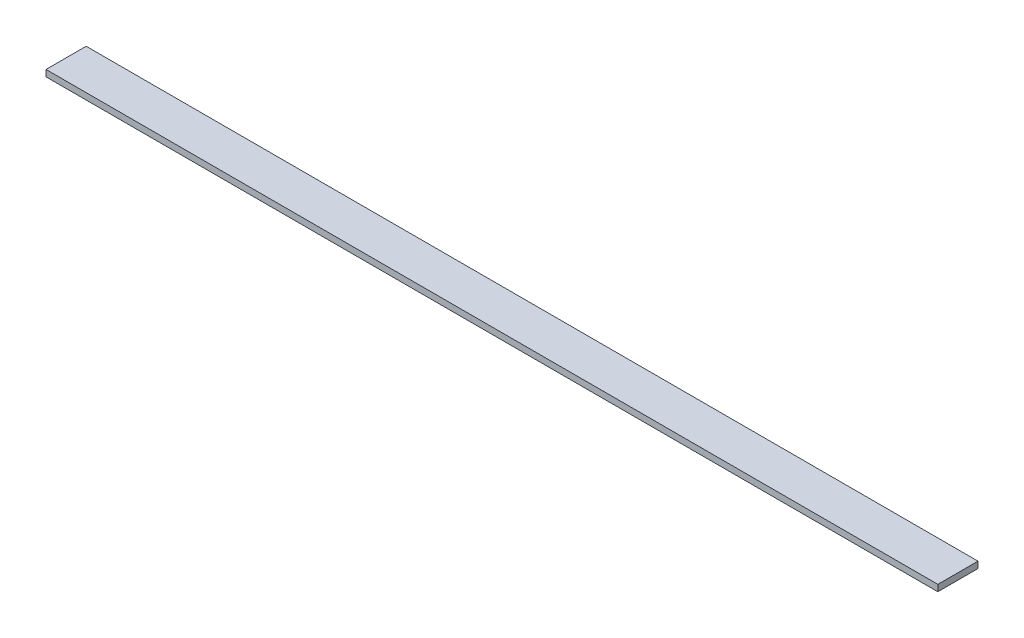
from build123d import *

# Parameters (mm, degrees)
SKETCH_1_W      = 555
SKETCH_1_H      = 25
EXTRUDE_1_DEPTH = 4


with BuildPart() as part:
    # 草图1 → 凸台-拉伸1 (new body)
    with BuildSketch(Plane(origin=(0, 0, 0), x_dir=(1, 0, 0), z_dir=(0, 1, 0))):
        Rectangle(SKETCH_1_W, SKETCH_1_H)
    extrude(amount=EXTRUDE_1_DEPTH)


solid = part.part
